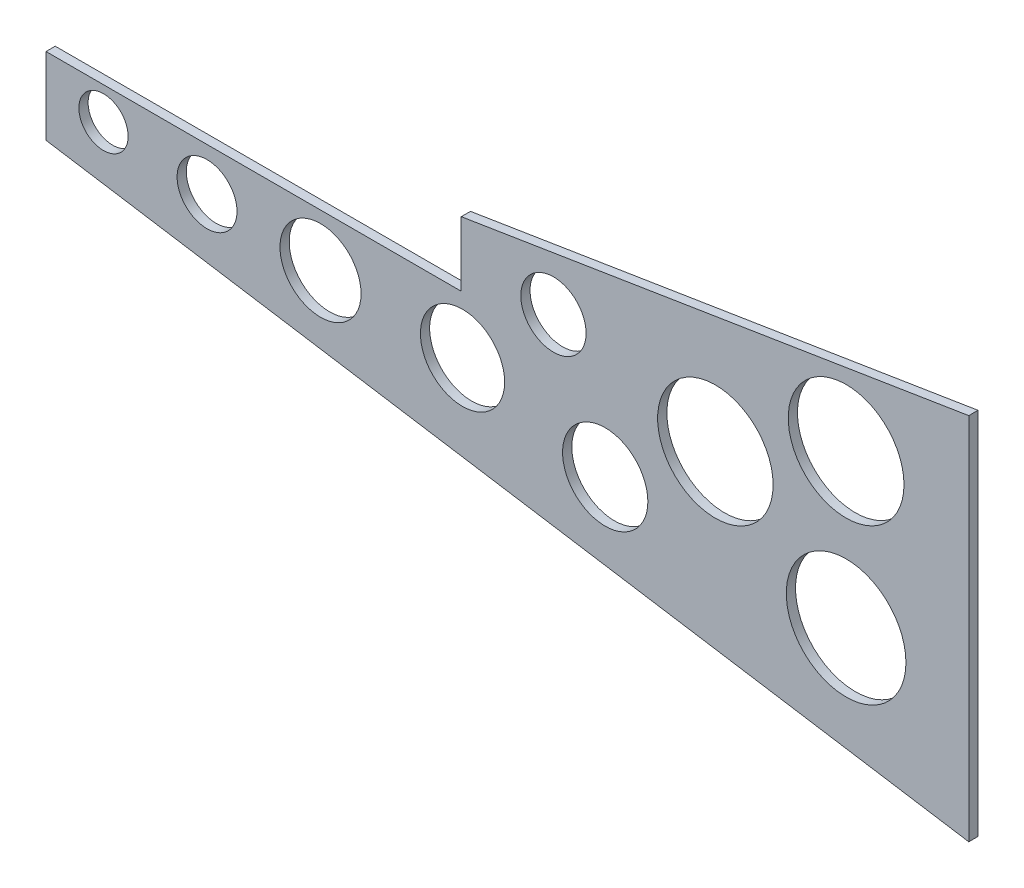
from build123d import *

# Parameters (mm, degrees)
BOSS_EXTRUDE1_DEPTH = 3
SKETCH2_R           = 8.006187357
SKETCH2_R_2         = 9.735262488
SKETCH2_R_3         = 13.182196279
SKETCH2_R_4         = 13.691397608
SKETCH2_R_5         = 19.450771096
SKETCH2_R_6         = 18.813943393
SKETCH2_R_7         = 18.770594662
SKETCH2_R_8         = 13.863766026
SKETCH2_R_9         = 10.613691542
CUT_EXTRUDE1_DEPTH  = 3


with BuildPart() as part:
    # Sketch1 → Boss-Extrude1 (new body)
    with BuildSketch(Plane.XY):
        Polygon((150, 56.603970605), (150, -63.396029395), (-150, -15.880697298), (-150, 9.119302702), (-15, 9.119302702), (-15, 30.119302702), align=None)
    extrude(amount=BOSS_EXTRUDE1_DEPTH)

    # Sketch2 → Cut-Extrude1 (cut)
    with BuildSketch(Plane.XY.offset(3)):
        with Locations((-131.306408306, -1.418891545)):
            Circle(SKETCH2_R)
        with Locations((-97.648790291, -4.870954931)):
            Circle(SKETCH2_R_2)
        with Locations((-60.754862852, -7.891510394)):
            Circle(SKETCH2_R_3)
        with Locations((-14.583515063, -9.425078902)):
            Circle(SKETCH2_R_4)
        with Locations((110.12227476, -23.116476509)):
            Circle(SKETCH2_R_5)
        with Locations((110.12227476, 26.629123467)):
            Circle(SKETCH2_R_6)
        with Locations((67.618744319, 5.290685885)):
            Circle(SKETCH2_R_7)
        with Locations((31.803586688, -19.757978284)):
            Circle(SKETCH2_R_8)
        with Locations((14.974777681, 17.567457079)):
            Circle(SKETCH2_R_9)
    extrude(amount=-CUT_EXTRUDE1_DEPTH, mode=Mode.SUBTRACT)


solid = part.part
